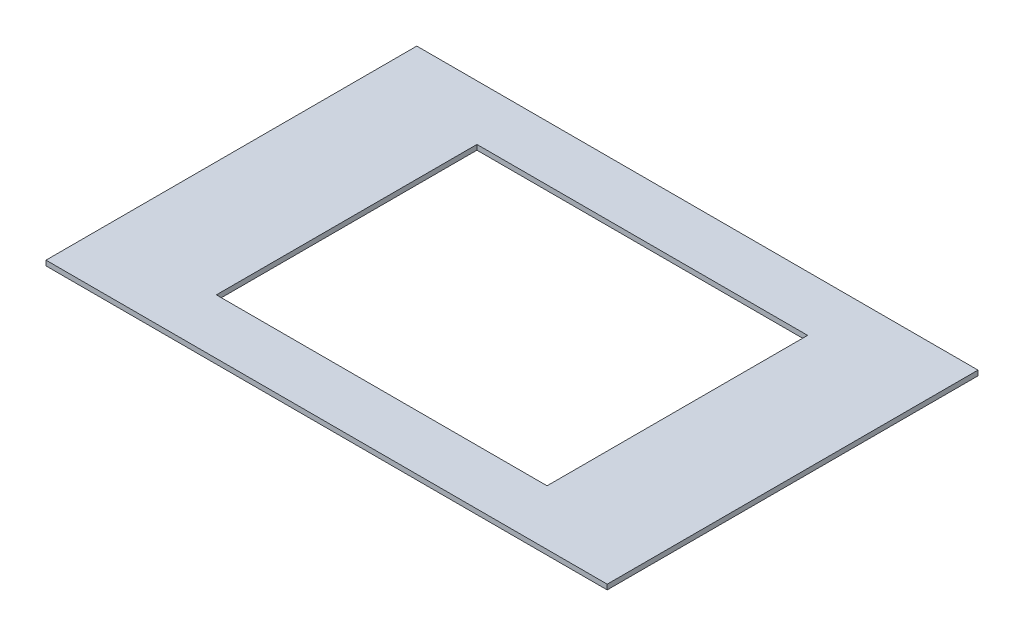
from build123d import *

# Parameters (mm, degrees)
SKETCH1_W           = 112
SKETCH1_H           = 74
BOSS_EXTRUDE1_DEPTH = 1
SKETCH5_W           = 66
SKETCH5_H           = 52
CUT_EXTRUDE2_DEPTH  = 2


with BuildPart() as part:
    # Sketch1 → Boss-Extrude1 (new body)
    with BuildSketch(Plane(origin=(0, 0, 0), x_dir=(1, 0, 0), z_dir=(0, 1, 0))):
        Rectangle(SKETCH1_W, SKETCH1_H)
    extrude(amount=BOSS_EXTRUDE1_DEPTH)

    # Sketch5 → Cut-Extrude2 (cut)
    with BuildSketch(Plane(origin=(0, 1, 0), x_dir=(1, 0, 0), z_dir=(0, 1, 0))):
        Rectangle(SKETCH5_W, SKETCH5_H)
    extrude(amount=-CUT_EXTRUDE2_DEPTH, mode=Mode.SUBTRACT)


solid = part.part
